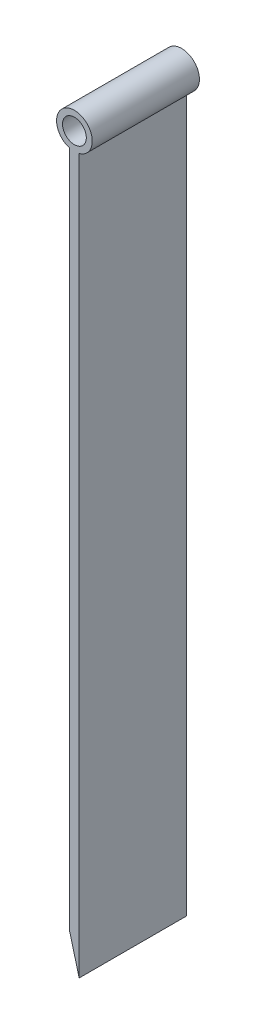
from build123d import *

# Parameters (mm, degrees)
CROQUIS3_R              = 3.75
CROQUIS3_R_2            = 2.5
SALIENTE_EXTRUIR1_DEPTH = 22.5


with BuildPart() as part:
    # Croquis3 → Saliente-Extruir1 (new body)
    with BuildSketch(Plane.XY):
        with Locations((-1, 153.5)):
            Circle(CROQUIS3_R)
        with Locations((-1, 153.5)):
            Circle(CROQUIS3_R_2, mode=Mode.SUBTRACT)
        with BuildLine():
            Line((0, 0), (0, 149.885791926))
            ThreePointArc((0, 149.885791926), (-1, 149.75), (-2, 149.885791926))
            Line((-2, 149.885791926), (-2, 7.5))
            Line((-2, 7.5), (0, 0))
        make_face()
    extrude(amount=SALIENTE_EXTRUIR1_DEPTH)


solid = part.part
